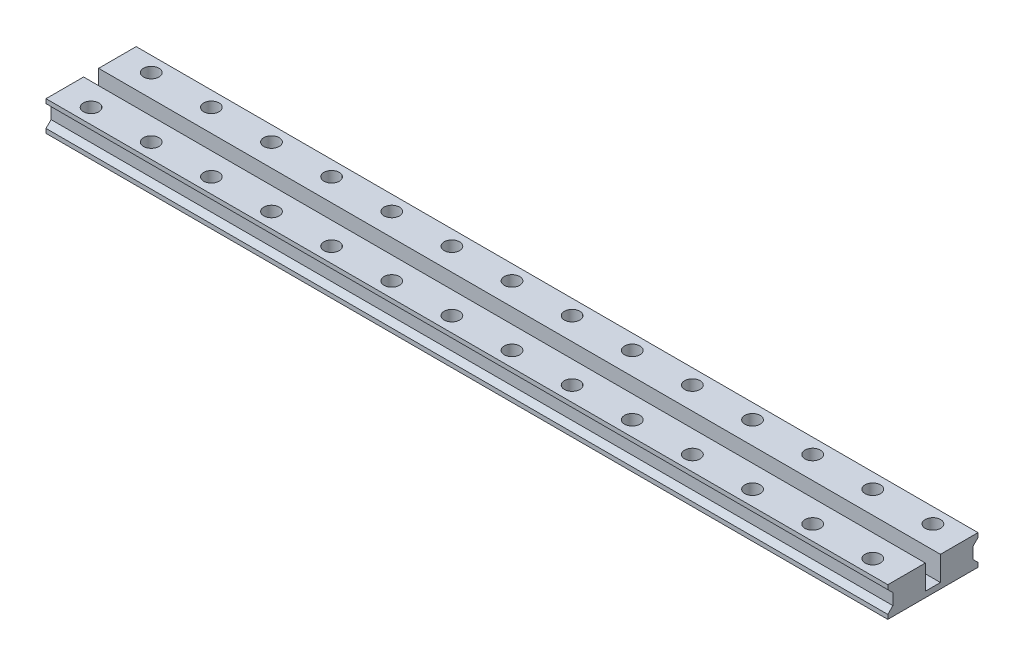
from build123d import *

# Parameters (mm, degrees)
SKETCH1_W           = 224
SKETCH1_H           = 24
BOSS_EXTRUDE1_DEPTH = 8
SKETCH2_R           = 2.05
CUT_EXTRUDE1_DEPTH  = 9
SKETCH3_W           = 4
SKETCH3_H           = 6.5
CUT_EXTRUDE2_DEPTH  = 225


with BuildPart() as part:
    # Sketch1 → Boss-Extrude1 (new body)
    with BuildSketch(Plane(origin=(0, 0, 0), x_dir=(1, 0, 0), z_dir=(0, 1, 0))):
        Rectangle(SKETCH1_W, SKETCH1_H)
    extrude(amount=BOSS_EXTRUDE1_DEPTH)

    # Sketch2 → Cut-Extrude1 (cut, through all)
    with BuildSketch(Plane(origin=(0, 8, 0), x_dir=(1, 0, 0), z_dir=(0, 1, 0))):
        with Locations((-104, 8)):
            Circle(SKETCH2_R)
        with Locations((-88, 8)):
            Circle(SKETCH2_R)
        with Locations((-72, 8)):
            Circle(SKETCH2_R)
        with Locations((-56, 8)):
            Circle(SKETCH2_R)
        with Locations((-40, 8)):
            Circle(SKETCH2_R)
        with Locations((-24, 8)):
            Circle(SKETCH2_R)
        with Locations((-8, 8)):
            Circle(SKETCH2_R)
        with Locations((8, 8)):
            Circle(SKETCH2_R)
        with Locations((24, 8)):
            Circle(SKETCH2_R)
        with Locations((40, 8)):
            Circle(SKETCH2_R)
        with Locations((56, 8)):
            Circle(SKETCH2_R)
        with Locations((72, 8)):
            Circle(SKETCH2_R)
        with Locations((88, 8)):
            Circle(SKETCH2_R)
        with Locations((104, 8)):
            Circle(SKETCH2_R)
        with Locations((-88, -8)):
            Circle(SKETCH2_R)
        with Locations((-72, -8)):
            Circle(SKETCH2_R)
        with Locations((-56, -8)):
            Circle(SKETCH2_R)
        with Locations((-40, -8)):
            Circle(SKETCH2_R)
        with Locations((-24, -8)):
            Circle(SKETCH2_R)
        with Locations((-8, -8)):
            Circle(SKETCH2_R)
        with Locations((8, -8)):
            Circle(SKETCH2_R)
        with Locations((24, -8)):
            Circle(SKETCH2_R)
        with Locations((40, -8)):
            Circle(SKETCH2_R)
        with Locations((56, -8)):
            Circle(SKETCH2_R)
        with Locations((72, -8)):
            Circle(SKETCH2_R)
        with Locations((88, -8)):
            Circle(SKETCH2_R)
        with Locations((104, -8)):
            Circle(SKETCH2_R)
        with Locations((-104, -8)):
            Circle(SKETCH2_R)
    extrude(amount=-CUT_EXTRUDE1_DEPTH, mode=Mode.SUBTRACT)

    # Sketch3 → Cut-Extrude2 (cut, through all)
    with BuildSketch(Plane.ZY.offset(112)):
        with Locations((0, 4.75)):
            Rectangle(SKETCH3_W, SKETCH3_H)
        Polygon((-12, 6.85), (-10.65, 5.5), (-10.65, 2.5), (-12, 1.15), align=None)
        Polygon((12, 6.85), (12, 1.15), (10.65, 2.5), (10.65, 5.5), align=None)
    extrude(amount=-CUT_EXTRUDE2_DEPTH, mode=Mode.SUBTRACT)


solid = part.part
